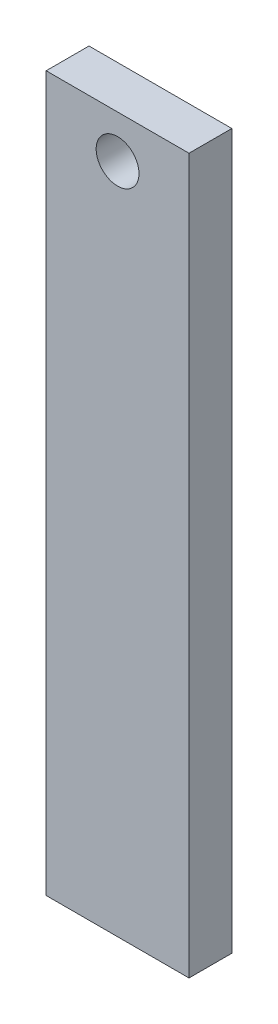
from build123d import *

# Parameters (mm, degrees)
SKETCH1_W           = 50
SKETCH1_H           = 15
BOSS_EXTRUDE1_DEPTH = 250
SKETCH2_R           = 7.5
CUT_EXTRUDE2_DEPTH  = 16


with BuildPart() as part:
    # Sketch1 → Boss-Extrude1 (new body)
    with BuildSketch(Plane(origin=(0, 0, 0), x_dir=(1, 0, 0), z_dir=(0, 1, 0))):
        Rectangle(SKETCH1_W, SKETCH1_H)
    extrude(amount=BOSS_EXTRUDE1_DEPTH)

    # Sketch2 → Cut-Extrude2 (cut, through all)
    with BuildSketch(Plane.XY.offset(7.5)):
        with Locations((0, 235.049185274)):
            Circle(SKETCH2_R)
    extrude(amount=-CUT_EXTRUDE2_DEPTH, mode=Mode.SUBTRACT)


solid = part.part
